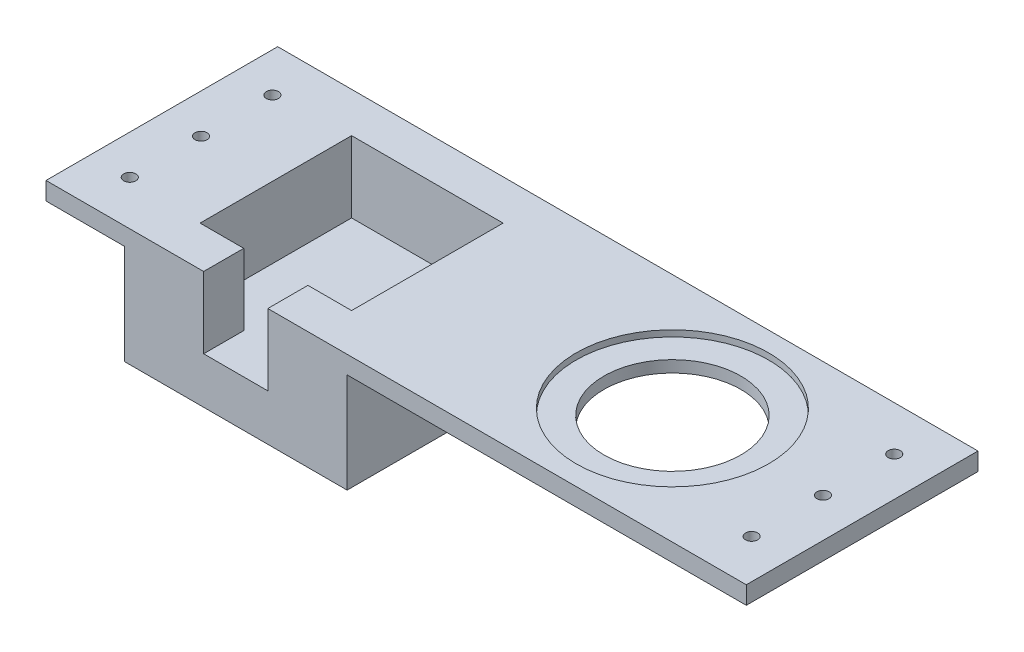
from build123d import *

# Parameters (mm, degrees)
SKETCH2_W            = 196.45
SKETCH2_H            = 65
BOSS_EXTRUDE1_DEPTH  = 5
BOSS_EXTRUDE2_DEPTH  = 28
BOSS_EXTRUDE3_DEPTH  = 20
CUT_EXTRUDE9_START   = -33
CUT_EXTRUDE9_DEPTH   = 20
SKETCH4_R            = 26.99
CUT_EXTRUDE3_DEPTH   = 1.74
SKETCH3_4_R          = 19.2
CUT_EXTRUDE10_DEPTH  = 20
M3_CLEARANCE_HOLE1_D = 3.4


with BuildPart() as part:
    # Sketch2 → Boss-Extrude1 (new body)
    with BuildSketch(Plane(origin=(0, 0, 0), x_dir=(1, 0, 0), z_dir=(0, 1, 0))):
        Rectangle(SKETCH2_W, SKETCH2_H)
    extrude(amount=BOSS_EXTRUDE1_DEPTH)

    # Sketch3 → Boss-Extrude2 (add)
    with BuildSketch(Plane(origin=(0, 0, 0), x_dir=(1, 0, 0), z_dir=(0, 1, 0))):
        Polygon((-36, -32.5), (-36, -21.25), (-23.75, -21.25), (-23.75, 21.25), (-66.25, 21.25), (-66.25, -21.25), (-54, -21.25), (-54, -32.5), (-76.25, -32.5), (-76.25, 32.5), (-13.75, 32.5), (-13.75, -32.5), align=None)
    extrude(amount=-BOSS_EXTRUDE2_DEPTH)

    # Sketch12 → Boss-Extrude3 (add)
    with BuildSketch(Plane.XZ.offset(28)):
        Polygon((-36, 21.25), (-36, 32.5), (-54, 32.5), (-54, 21.25), (-66.25, 21.25), (-66.25, -21.25), (-23.75, -21.25), (-23.75, 21.25), align=None)
    extrude(amount=-BOSS_EXTRUDE3_DEPTH)

    # Sketch12_2 → Cut-Extrude9 (cut)
    with BuildSketch(Plane.XZ.offset(28).offset(CUT_EXTRUDE9_START)):
        Polygon((-36, 21.25), (-36, 32.5), (-54, 32.5), (-54, 21.25), (-66.25, 21.25), (-66.25, -21.25), (-23.75, -21.25), (-23.75, 21.25), align=None)
    extrude(amount=CUT_EXTRUDE9_DEPTH, mode=Mode.SUBTRACT)

    # Sketch4 → Cut-Extrude3 (cut)
    with BuildSketch(Plane(origin=(0, 5, 0), x_dir=(1, 0, 0), z_dir=(0, 1, 0))):
        with Locations((45, 0)):
            Circle(SKETCH4_R)
    extrude(amount=-CUT_EXTRUDE3_DEPTH, mode=Mode.SUBTRACT)

    # Sketch3_4 → Cut-Extrude10 (cut)
    with BuildSketch(Plane(origin=(0, 0, 0), x_dir=(1, 0, 0), z_dir=(0, 1, 0))):
        with Locations((45, 0)):
            Circle(SKETCH3_4_R)
    extrude(amount=CUT_EXTRUDE10_DEPTH, mode=Mode.SUBTRACT)

    # M3 Clearance Hole1 (through all)
    with Locations(Plane(origin=(0, 5, 0), x_dir=(1, 0, 0), z_dir=(0, 1, 0))):
        with Locations((-87.225, 20), (-87.225, 0), (-87.225, -20), (87.225, -20), (87.225, 0), (87.225, 20)):
            Hole(M3_CLEARANCE_HOLE1_D / 2)


solid = part.part
